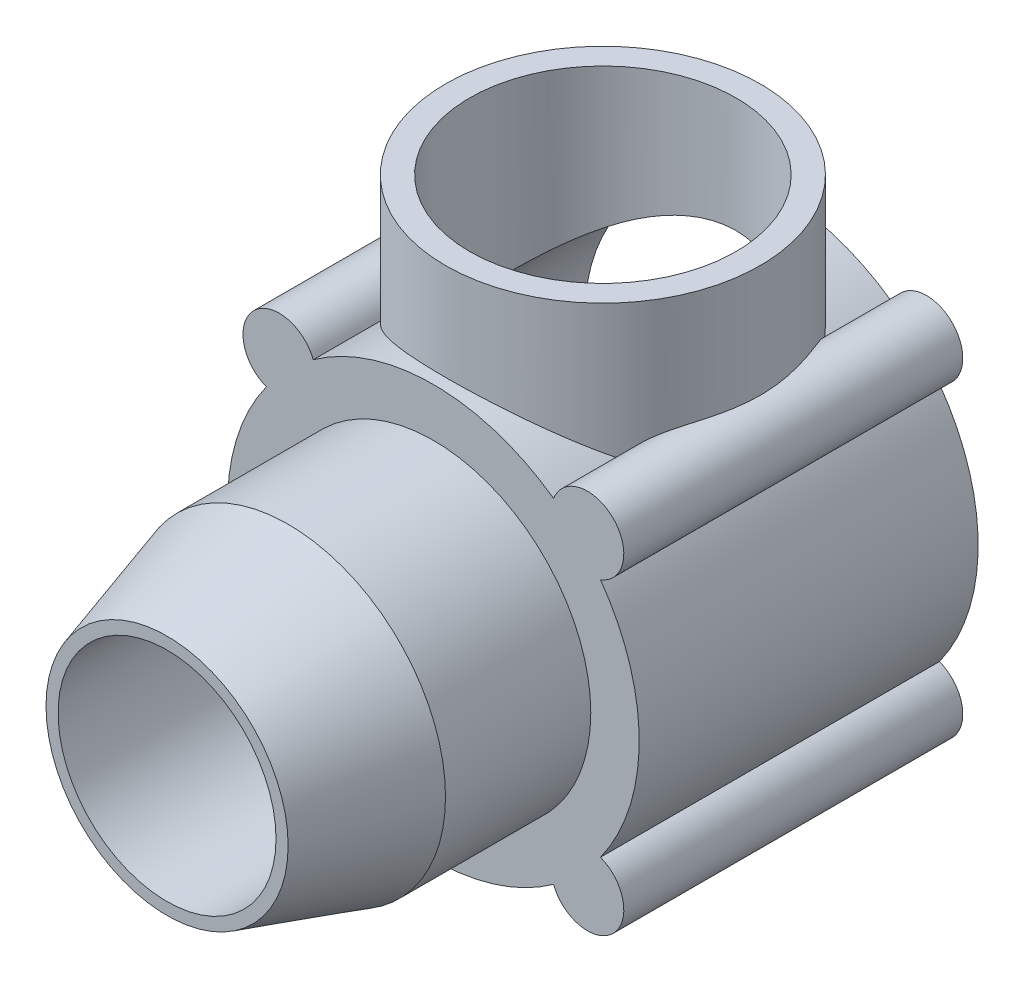
from build123d import *

# Parameters (mm, degrees)
SKETCH1_R           = 17
BOSS_EXTRUDE1_DEPTH = 14
SKETCH2_R           = 13
BOSS_EXTRUDE2_DEPTH = 22
SKETCH3_R           = 13
BOSS_EXTRUDE3_DEPTH = 25
SKETCH4_R           = 15.5
CUT_EXTRUDE1_DEPTH  = 25
SKETCH5_R           = 9
CUT_EXTRUDE2_DEPTH  = 25
CHAMFER2_SIZE       = 10
CHAMFER2_SIZE2      = 3
BOSS_EXTRUDE4_DEPTH = 28
CIRPATTERN1_COUNT   = 4
SKETCH6_R           = 11
CUT_EXTRUDE3_DEPTH  = 25
CIRPATTERN2_COUNT   = 4


with BuildPart() as part:
    # Sketch1 → Boss-Extrude1 (new body, symmetric)
    with BuildSketch(Plane.XY):
        Circle(SKETCH1_R)
    extrude(amount=BOSS_EXTRUDE1_DEPTH, both=True)

    # Sketch2 → Boss-Extrude2 (add)
    with BuildSketch(Plane.XY.offset(14)):
        Circle(SKETCH2_R)
    extrude(amount=BOSS_EXTRUDE2_DEPTH)

    # Sketch3 → Boss-Extrude3 (add)
    with BuildSketch(Plane(origin=(0, 0, 0), x_dir=(1, 0, 0), z_dir=(0, 1, 0))):
        with Locations(Location((0, 0, 0), (0, 0, 90))):  # turned: the seam where the file's is
            Circle(SKETCH3_R)
    extrude(amount=BOSS_EXTRUDE3_DEPTH)

    # Sketch4 → Cut-Extrude1 (cut)
    with BuildSketch(Plane(origin=(0, 0, -14), x_dir=(-1, 0, 0), z_dir=(0, 0, -1))):
        Circle(SKETCH4_R)
    extrude(amount=-CUT_EXTRUDE1_DEPTH, mode=Mode.SUBTRACT)

    # Sketch5 → Cut-Extrude2 (cut)
    with BuildSketch(Plane.XY.offset(36)):
        Circle(SKETCH5_R)
    extrude(amount=-CUT_EXTRUDE2_DEPTH, mode=Mode.SUBTRACT)

    # Chamfer2
    chamfer2_edges = [part.edges().sort_by_distance(p)[0] for p in [
        (-13, 0, 36),
    ]]
    chamfer2_side = [part.faces().sort_by_distance(p)[0] for p in [
        (-13, 0, 25),
    ]]
    chamfer(chamfer2_edges, length=CHAMFER2_SIZE, length2=CHAMFER2_SIZE2, reference=chamfer2_side[0])

    # Sketch7 → Boss-Extrude4 (add)
    with BuildSketch(Plane(origin=(0, 0, -14), x_dir=(-1, 0, 0), z_dir=(0, 0, -1))):
        with BuildLine():
            ThreePointArc((-9.819351092, 11.992928922), (-14.849242405, 14.849242405), (-11.992928922, 9.819351092))
            ThreePointArc((-11.992928922, 9.819351092), (-10.960155108, 10.960155108), (-9.819351092, 11.992928922))
        make_face()
    boss_extrude4 = extrude(amount=-BOSS_EXTRUDE4_DEPTH)

    # CirPattern1: Boss-Extrude4 ×4 about axis
    cirpattern1_axis = Axis((0, 0, 0), (0, 0, 1))
    for i in range(1, CIRPATTERN1_COUNT):
        add(boss_extrude4.rotate(cirpattern1_axis, i * 360 / CIRPATTERN1_COUNT))

    # Sketch6 → Cut-Extrude3 (cut)
    with BuildSketch(Plane(origin=(0, 25, 0), x_dir=(1, 0, 0), z_dir=(0, 1, 0))):
        with Locations(Location((0, 0, 0), (0, 0, 270))):  # turned: the seam where the file's is
            Circle(SKETCH6_R)
    extrude(amount=-CUT_EXTRUDE3_DEPTH, mode=Mode.SUBTRACT)

    # Sketch9 → Tap Drill for M3x0.5 Tap1 (revolve, cut)
    with BuildSketch(Plane(origin=(12.727922061, 12.727922061, -14), x_dir=(0, 1, 0), z_dir=(1, 0, 0))):
        Polygon((0, 0), (0, 9.751075774), (1.25, 9), (1.25, 0.25), (1.5, 0), align=None)
    tap_drill_for_m3x0_5_tap1 = revolve(axis=Axis((12.727922061, 12.727922061, -20.35), (0, 0, 1)), mode=Mode.SUBTRACT)

    # CirPattern2: Tap Drill for M3x0.5 Tap1 ×4 about axis
    cirpattern2_axis = Axis((0, 0, 0), (0, 0, 1))
    for i in range(1, CIRPATTERN2_COUNT):
        add(tap_drill_for_m3x0_5_tap1.rotate(cirpattern2_axis, i * 360 / CIRPATTERN2_COUNT), mode=Mode.SUBTRACT)


solid = part.part
